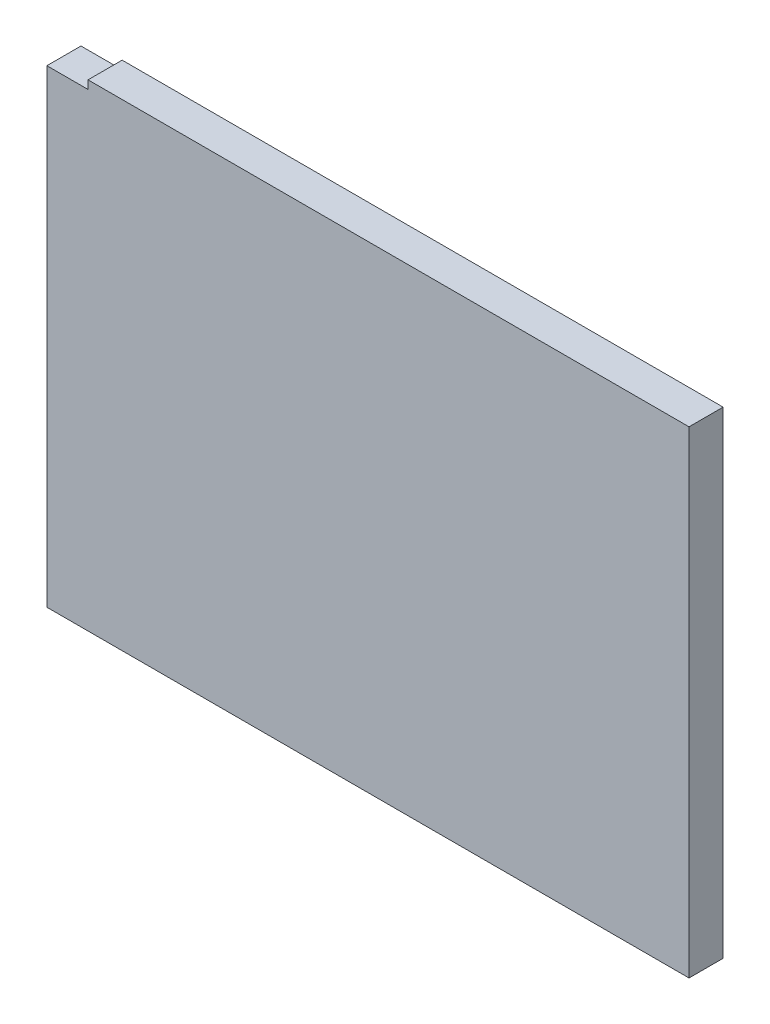
from build123d import *

# Parameters (mm, degrees)
SIDEOUTLINE_W               = 215.265
SIDEOUTLINE_H               = 160.02
SIDEOUTLINE_THICKNESS_DEPTH = 11.43
SKETCH2_W                   = 13.79855
SKETCH2_H                   = 2.794
CUT_EXTRUDE1_DEPTH          = 11.43


with BuildPart() as part:
    # SideOutline → SideOutline_Thickness (new body)
    with BuildSketch(Plane.XY):
        with Locations((-4873.3075, 1299.21)):
            Rectangle(SIDEOUTLINE_W, SIDEOUTLINE_H)
    extrude(amount=-SIDEOUTLINE_THICKNESS_DEPTH)

    # Sketch2 → Cut-Extrude1 (cut)
    with BuildSketch(Plane(origin=(0, 0, -11.43), x_dir=(-1, 0, 0), z_dir=(0, 0, -1))):
        with Locations((4974.040725, 1377.823)):
            Rectangle(SKETCH2_W, SKETCH2_H)
    extrude(amount=-CUT_EXTRUDE1_DEPTH, mode=Mode.SUBTRACT)


solid = part.part
